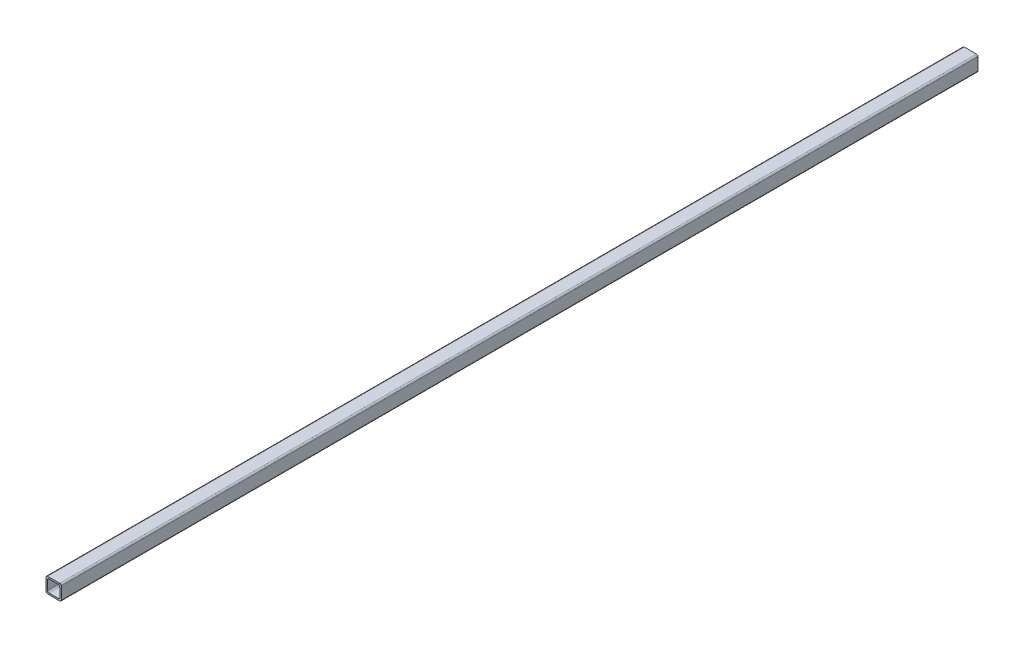
from build123d import *

# Parameters (mm, degrees)
SKETCH1_W           = 10
SKETCH1_H           = 10
SKETCH1_W_2         = 8
SKETCH1_H_2         = 8
BOSS_EXTRUDE1_DEPTH = 600
FILLET1_R           = 1
FILLET2_R           = 1


with BuildPart() as part:
    # Sketch1 → Boss-Extrude1 (new body)
    with BuildSketch(Plane.XY):
        with Locations((-2.879581152, 1.714659686)):
            Rectangle(SKETCH1_W, SKETCH1_H)
        with Locations((-2.879581152, 1.714659686)):
            Rectangle(SKETCH1_W_2, SKETCH1_H_2, mode=Mode.SUBTRACT)
    extrude(amount=BOSS_EXTRUDE1_DEPTH)

    # Fillet1
    fillet1_edges = [part.edges().sort_by_distance(p)[0] for p in [
        (-6.879581152, -2.285340314, 300),
        (2.120418848, -3.285340314, 300),
        (-7.879581152, 6.714659686, 300),
        (2.120418848, 6.714659686, 300),
    ]]
    fillet(fillet1_edges, radius=FILLET1_R)

    # Fillet2
    fillet2_edges = [part.edges().sort_by_distance(p)[0] for p in [
        (1.120418848, -2.285340314, 300),
        (1.120418848, 5.714659686, 300),
        (-6.879581152, 5.714659686, 300),
        (-7.879581152, -3.285340314, 300),
    ]]
    fillet(fillet2_edges, radius=FILLET2_R)


solid = part.part
